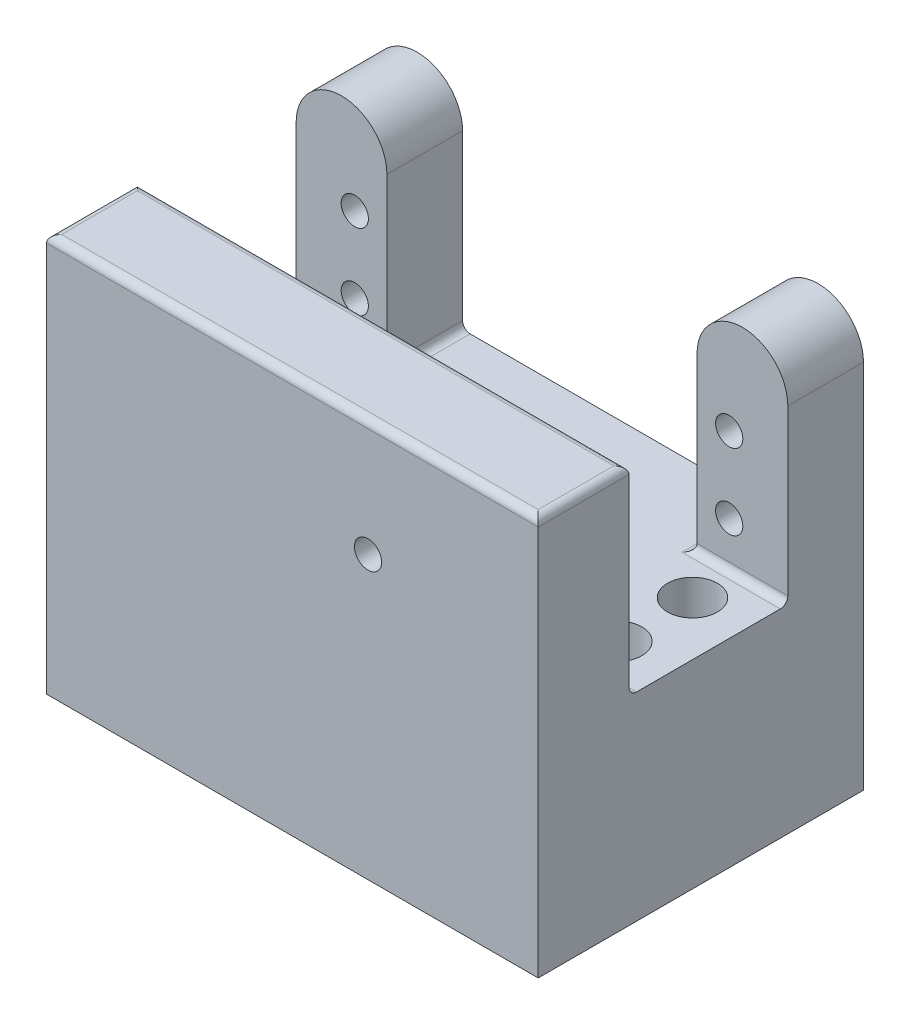
from build123d import *

# Parameters (mm, degrees)
BOSS_EXTRUDE1_DEPTH            = 10
SKETCH2_W                      = 12
SKETCH2_H                      = 12.25
BOSS_EXTRUDE2_DEPTH            = 21
SKETCH4_W                      = 65
SKETCH4_H                      = 38.636969104
BOSS_EXTRUDE3_DEPTH            = 12
F_3_6_3_6_DIAMETER_HOLE1_D     = 3.6
F_3_6_3_6_DIAMETER_HOLE1_DEPTH = 10
F_3_6_3_6_DIAMETER_HOLE1_TIP   = 1.081549114
SKETCH21_W                     = 41
SKETCH21_H                     = 12.25
BOSS_EXTRUDE4_DEPTH            = 31
SKETCH23_W                     = 65
SKETCH23_H                     = 43
BOSS_EXTRUDE6_DEPTH            = 14
FILLET1_R                      = 1
F_6_6_6_6_DIAMETER_HOLE1_D     = 6.6
SKETCH28_R                     = 1.8
CUT_EXTRUDE1_DEPTH             = 44


with BuildPart() as part:
    # Sketch1 → Boss-Extrude1 (new body)
    with BuildSketch(Plane.XY):
        with BuildLine():
            Line((-6, 14.302325581), (-6, -20.697674419))
            Line((-6, -20.697674419), (6, -20.697674419))
            Line((6, -20.697674419), (6, 14.302325581))
            ThreePointArc((6, 14.302325581), (0, 20.302325581), (-6, 14.302325581))
        make_face()
    boss_extrude1 = extrude(amount=BOSS_EXTRUDE1_DEPTH)

    # Sketch2 → Boss-Extrude2 (add)
    with BuildSketch(Plane.XY.offset(10)):
        with Locations((0, -14.572674419)):
            Rectangle(SKETCH2_W, SKETCH2_H)
    boss_extrude2 = extrude(amount=BOSS_EXTRUDE2_DEPTH)

    # Sketch4 → Boss-Extrude3 (add)
    with BuildSketch(Plane.XY.offset(31)):
        with Locations((-26.5, -1.379189867)):
            Rectangle(SKETCH4_W, SKETCH4_H)
    extrude(amount=BOSS_EXTRUDE3_DEPTH)

    # Mirror2: Boss-Extrude2 across plane
    add(boss_extrude2.mirror(Plane.ZY.offset(26.5)))

    # Mirror3: Boss-Extrude1 across plane
    add(boss_extrude1.mirror(Plane.ZY.offset(26.5)))

    # Ø3.6 (3.6) Diameter Hole1
    with Locations(Plane(origin=(0, 0, 0), x_dir=(-1, 0, 0), z_dir=(0, 0, -1))):
        with Locations((1.75, 7.55218084), (1.75, -2.44781916), (51.25, 8), (51.25, -2)):
            Hole(F_3_6_3_6_DIAMETER_HOLE1_D / 2, depth=F_3_6_3_6_DIAMETER_HOLE1_DEPTH)
            with Locations((0, 0, -(F_3_6_3_6_DIAMETER_HOLE1_DEPTH + F_3_6_3_6_DIAMETER_HOLE1_TIP / 2))):  # 118° drill point
                Cone(0, F_3_6_3_6_DIAMETER_HOLE1_D / 2, F_3_6_3_6_DIAMETER_HOLE1_TIP, mode=Mode.SUBTRACT)

    # Sketch21 → Boss-Extrude4 (add)
    with BuildSketch(Plane(origin=(0, 0, 31), x_dir=(-1, 0, 0), z_dir=(0, 0, -1))):
        with Locations((26.5, -14.572674419)):
            Rectangle(SKETCH21_W, SKETCH21_H)
    extrude(amount=BOSS_EXTRUDE4_DEPTH)

    # Sketch23 → Boss-Extrude6 (add)
    with BuildSketch(Plane.XZ.offset(20.697674419)):
        with Locations((-26.5, 21.5)):
            Rectangle(SKETCH23_W, SKETCH23_H)
    extrude(amount=BOSS_EXTRUDE6_DEPTH)

    # Fillet1
    fillet1_edges = [part.edges().sort_by_distance(p)[0] for p in [
        (-26.5, -8.447674419, 31),
        (0, -8.447674419, 10),
        (-26.5, 17.939294685, 31),
        (6, 17.939294685, 37),
        (-59, 17.939294685, 37),
        (-26.5, 17.939294685, 43),
        (-53, -8.447674419, 10),
        (-6, -8.447674419, 5),
        (-47, -8.447674419, 5),
    ]]
    fillet(fillet1_edges, radius=FILLET1_R)

    # Ø6.6 (6.6) Diameter Hole1 (through all)
    with Locations(Plane(origin=(0, -34.697674419, 0), x_dir=(-1, 0, 0), z_dir=(0, -1, 0))):
        with Locations((1.1, -15.5), (1.1, -25.5), (51.9, -15.5), (51.9, -25.5)):
            Hole(F_6_6_6_6_DIAMETER_HOLE1_D / 2)

    # Sketch28 → Cut-Extrude1 (cut, through all)
    with BuildSketch(Plane.XY.offset(43)):
        with Locations((-16.5, 2.553012267)):
            Circle(SKETCH28_R)
    extrude(amount=-CUT_EXTRUDE1_DEPTH, mode=Mode.SUBTRACT)


solid = part.part
